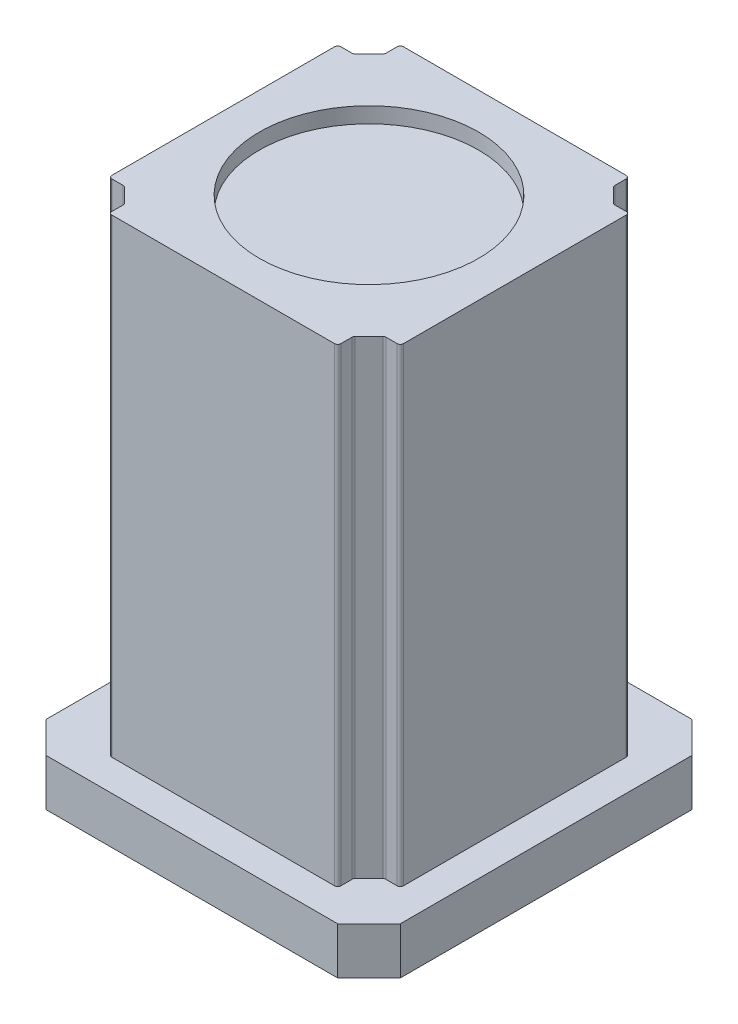
from build123d import *

# Parameters (mm, degrees)
BOSS_EXTRUDE1_DEPTH = 15
BOSS_EXTRUDE2_DEPTH = 150
FILLET1_R           = 1
SKETCH3_R           = 35
CUT_EXTRUDE1_DEPTH  = 5


with BuildPart() as part:
    # Sketch1 → Boss-Extrude1 (new body)
    with BuildSketch(Plane(origin=(0, 0, 0), x_dir=(1, 0, 0), z_dir=(0, 1, 0))):
        Polygon((-56.565, 46.565), (-46.565, 56.565), (46.565, 56.565), (56.565, 46.565), (56.565, -46.565), (46.565, -56.565), (-46.565, -56.565), (-56.565, -46.565), align=None)
    extrude(amount=BOSS_EXTRUDE1_DEPTH)

    # Sketch2 → Boss-Extrude2 (add)
    with BuildSketch(Plane(origin=(0, 15, 0), x_dir=(1, 0, 0), z_dir=(0, 1, 0))):
        Polygon((36.565, 46.565), (36.565, 41.565), (41.565, 36.565), (46.565, 36.565), (46.565, -36.565), (41.565, -36.565), (36.565, -41.565), (36.565, -46.565), (-36.565, -46.565), (-36.565, -41.565), (-41.565, -36.565), (-46.565, -36.565), (-46.565, 36.565), (-41.565, 36.565), (-36.565, 41.565), (-36.565, 46.565), align=None)
    extrude(amount=BOSS_EXTRUDE2_DEPTH)

    # Fillet1
    fillet1_edges = [part.edges().sort_by_distance(p)[0] for p in [
        (36.565, 90, -46.565),
        (-36.565, 90, -46.565),
        (-36.565, 90, -41.565),
        (-41.565, 90, -36.565),
        (-46.565, 90, -36.565),
        (-46.565, 90, 36.565),
        (-41.565, 90, 36.565),
        (-36.565, 90, 41.565),
        (-36.565, 90, 46.565),
        (36.565, 90, 46.565),
        (36.565, 90, 41.565),
        (41.565, 90, 36.565),
        (46.565, 90, 36.565),
        (46.565, 90, -36.565),
        (41.565, 90, -36.565),
        (36.565, 90, -41.565),
    ]]
    fillet(fillet1_edges, radius=FILLET1_R)

    # Sketch3 → Cut-Extrude1 (cut)
    with BuildSketch(Plane(origin=(0, 165, 0), x_dir=(1, 0, 0), z_dir=(0, 1, 0))):
        Circle(SKETCH3_R)
    extrude(amount=-CUT_EXTRUDE1_DEPTH, mode=Mode.SUBTRACT)


solid = part.part
